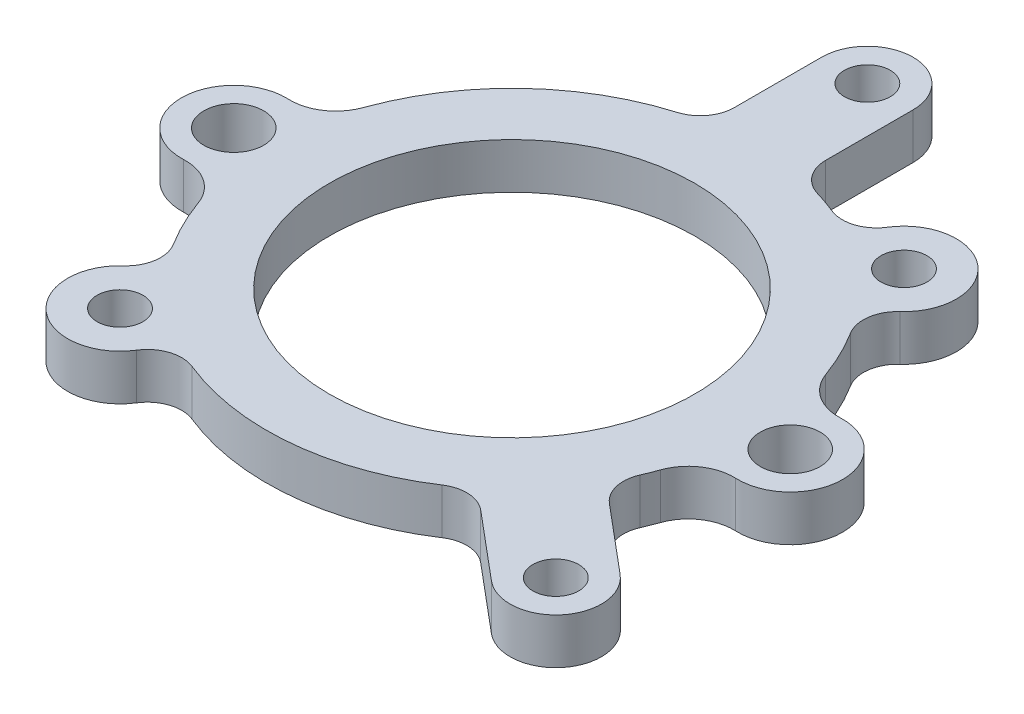
from build123d import *

# Parameters (mm, degrees)
SKETCH1_R               = 20.32
SKETCH1_R_2             = 3.3274
BOSS_EXTRUDE1_DEPTH     = 5.08
F_1_4_20_TAPPED_HOLE1_D = 5.1054


with BuildPart() as part:
    # Sketch1 → Boss-Extrude1 (new body)
    with BuildSketch(Plane(origin=(0, 0, 0), x_dir=(1, 0, 0), z_dir=(0, 1, 0))):
        with BuildLine():
            Line((19.57652647, -23.05812517), (27.015058429, -29.299794594))
            ThreePointArc((27.015058429, -29.299794594), (34.171925257, -28.67364988), (33.545780543, -21.516783052))
            Line((33.545780543, -21.516783052), (26.107248584, -15.275113628))
            ThreePointArc((26.107248584, -15.275113628), (24.848469725, -13.233023939), (25.059583331, -10.843445406))
            ThreePointArc((25.059583331, -10.843445406), (25.400007253, -10.020112603), (25.713388999, -9.186111864))
            ThreePointArc((25.713388999, -9.186111864), (27.657978886, -6.682698723), (30.708135247, -5.81953399))
            ThreePointArc((30.708135247, -5.81953399), (36.774453721, 0), (30.708135247, 5.81953399))
            ThreePointArc((30.708135247, 5.81953399), (27.657978886, 6.682698723), (25.713388999, 9.186111864))
            ThreePointArc((25.713388999, 9.186111864), (24.562302912, 11.927124576), (23.12004719, 14.526749221))
            ThreePointArc((23.12004719, 14.526749221), (22.572337736, 17.077966647), (23.794690624, 19.383297298))
            ThreePointArc((23.794690624, 19.383297298), (23.638163205, 28.170865922), (14.956916793, 26.79907006))
            ThreePointArc((14.956916793, 26.79907006), (12.898868646, 25.194970992), (10.291301197, 25.291345252))
            ThreePointArc((10.291301197, 25.291345252), (9.056948556, 25.759167453), (7.801428571, 26.166786911))
            ThreePointArc((7.801428571, 26.166786911), (5.835204005, 27.541055979), (5.08, 29.81796648))
            Line((5.08, 29.81796648), (5.08, 39.528280321))
            ThreePointArc((5.08, 39.528280321), (0, 44.608280321), (-5.08, 39.528280321))
            Line((-5.08, 39.528280321), (-5.08, 29.81796648))
            ThreePointArc((-5.08, 29.81796648), (-5.835204005, 27.541055979), (-7.801428571, 26.166786911))
            ThreePointArc((-7.801428571, 26.166786911), (-18.785541793, 19.815812992), (-25.713388999, 9.186111864))
            ThreePointArc((-25.713388999, 9.186111864), (-27.657978886, 6.682698723), (-30.708135247, 5.81953399))
            ThreePointArc((-30.708135247, 5.81953399), (-36.774453721, 0), (-30.708135247, -5.81953399))
            ThreePointArc((-30.708135247, -5.81953399), (-27.657978886, -6.682698723), (-25.713388999, -9.186111864))
            ThreePointArc((-25.713388999, -9.186111864), (-24.562302912, -11.927124576), (-23.12004719, -14.526749221))
            ThreePointArc((-23.12004719, -14.526749221), (-22.572337736, -17.077966647), (-23.794690624, -19.383297298))
            ThreePointArc((-23.794690624, -19.383297298), (-23.638163205, -28.170865922), (-14.956916793, -26.79907006))
            ThreePointArc((-14.956916793, -26.79907006), (-12.898868646, -25.194970992), (-10.291301197, -25.291345252))
            ThreePointArc((-10.291301197, -25.291345252), (2.67791157, -27.173365905), (15.030260084, -22.795927417))
            ThreePointArc((15.030260084, -22.795927417), (17.346876056, -22.173075144), (19.57652647, -23.05812517))
        make_face()
        Circle(SKETCH1_R, mode=Mode.SUBTRACT)
        with Locations((-30.9499, 0)):
            Circle(SKETCH1_R_2, mode=Mode.SUBTRACT)
        with Locations((30.9499, 0)):
            Circle(SKETCH1_R_2, mode=Mode.SUBTRACT)
    extrude(amount=BOSS_EXTRUDE1_DEPTH)

    # 1/4-20 Tapped Hole1 (through all)
    with Locations(Plane(origin=(0, 5.08, -39.528280321), x_dir=(0, 0, 1), z_dir=(0, 1, 0))):
        with Locations((0, 0), (15.819281411, 19.894212241), (64.936569144, 30.280419486), (63.237279231, -19.894212241)):
            Hole(F_1_4_20_TAPPED_HOLE1_D / 2)


solid = part.part
